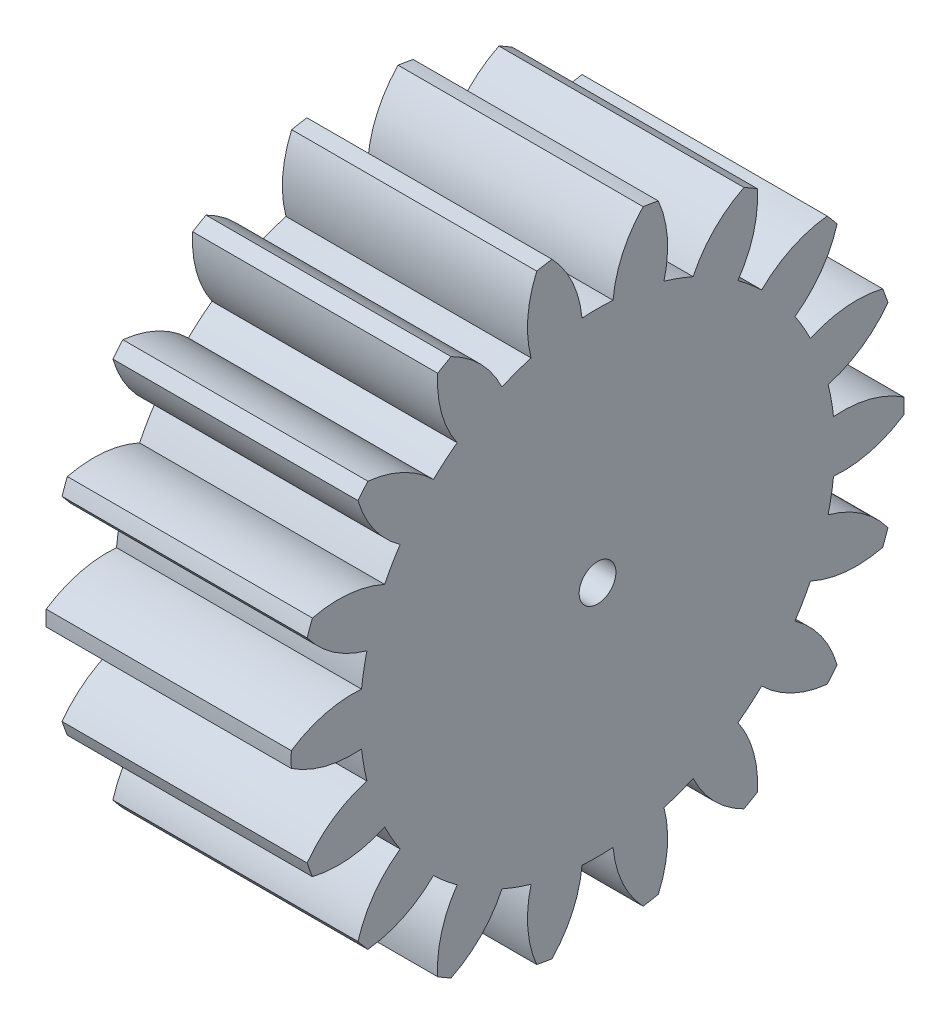
from build123d import *

# Parameters (mm, degrees)
BASPROSKE_W     = 20
BASPROSKE_H     = 25
TOOTHCUT_DEPTH  = 41.620192023
TEETHCUTS_COUNT = 18
TEETHCUTS_ANGLE = 340
BORSKE_R        = 1.5
BORE_DEPTH      = 50.0000508


with BuildPart() as part:
    # BasProSke → Base-Revolve (revolve)
    with BuildSketch(Plane(origin=(0, 0, 0), x_dir=(1, 0, 0), z_dir=(0, 1, 0)), mode=Mode.PRIVATE) as base_revolve_sk:
        with Locations((10, 12.5)):
            Rectangle(BASPROSKE_W, BASPROSKE_H)
    revolve(base_revolve_sk.sketch.rotate(Axis((-10, 0, 0), (1, 0, 0)), 180), axis=Axis((-10, 0, 0), (1, 0, 0)))

    # TooCutSke → ToothCut (cut, through all)
    with BuildSketch(Plane(origin=(0, 0, 0), x_dir=(0, 0, -1), z_dir=(1, 0, 0))):
        with BuildLine():
            ThreePointArc((1.264674858, 19.332678901), (0, 19.374), (-1.264674858, 19.332678901))
            ThreePointArc((-1.264674858, 19.332678901), (-2.042144439, 22.249025962), (-3.740062307, 24.744344386))
            ThreePointArc((-3.740062307, 24.744344386), (0, 25.0254), (3.740062307, 24.744344386))
            ThreePointArc((3.740062307, 24.744344386), (2.042144439, 22.249025962), (1.264674858, 19.332678901))
        make_face()
    toothcut = extrude(amount=TOOTHCUT_DEPTH, mode=Mode.SUBTRACT)

    # TeethCuts: ToothCut ×18 about axis
    teethcuts_axis = Axis((-10, 0, 0), (1, 0, 0))
    for i in range(1, TEETHCUTS_COUNT):
        add(toothcut.rotate(teethcuts_axis, i * TEETHCUTS_ANGLE / (TEETHCUTS_COUNT - 1)), mode=Mode.SUBTRACT)

    # BorSke → Bore (cut, symmetric)
    with BuildSketch(Plane(origin=(0, 0, 0), x_dir=(0, 0, -1), z_dir=(1, 0, 0))):
        with Locations(Location((0, 0, 0), (0, 0, 180))):
            Circle(BORSKE_R)
    extrude(amount=BORE_DEPTH, both=True, mode=Mode.SUBTRACT)


solid = part.part
